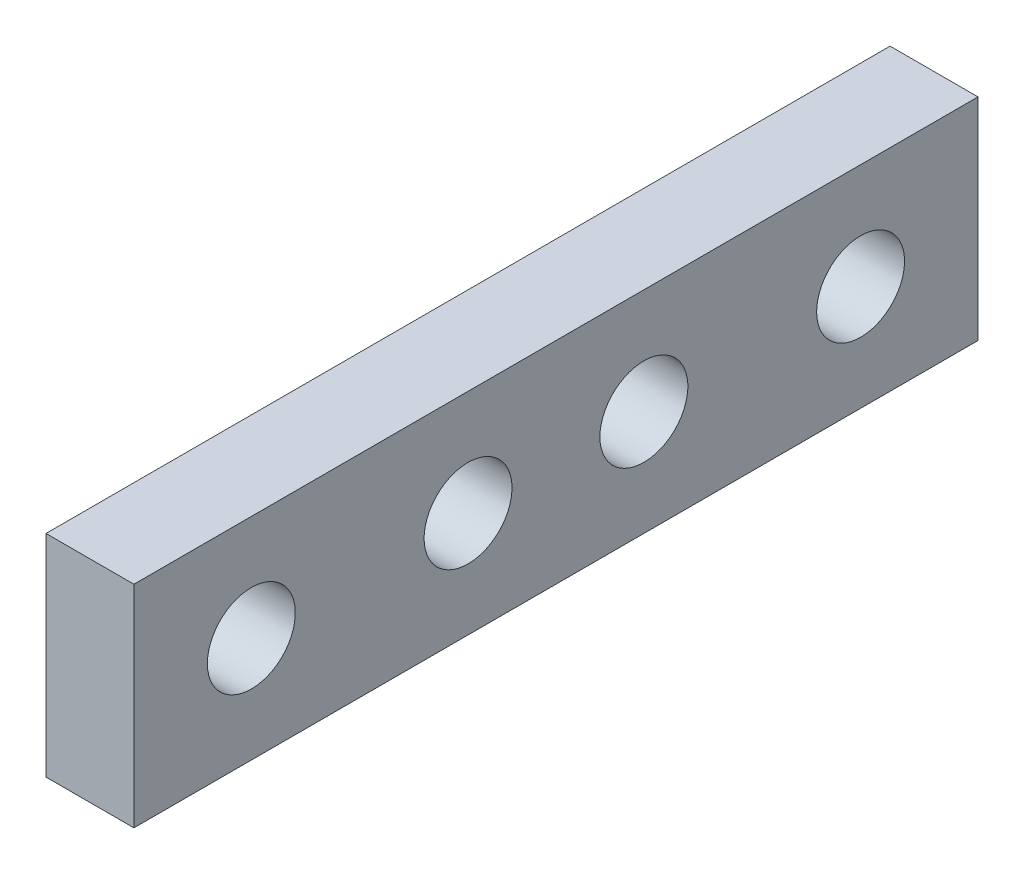
from build123d import *

# Parameters (mm, degrees)
SKETCH1_W           = 3.175
SKETCH1_H           = 7.62
BOSS_EXTRUDE1_DEPTH = 15.24
SKETCH3_R           = 1.5875
CUT_EXTRUDE2_DEPTH  = 4.175
SKETCH5_R           = 1.5875
CUT_EXTRUDE4_DEPTH  = 4.175


with BuildPart() as part:
    # Sketch1 → Boss-Extrude1 (new body)
    with BuildSketch(Plane.XY):
        Rectangle(SKETCH1_W, SKETCH1_H)
    boss_extrude1 = extrude(amount=BOSS_EXTRUDE1_DEPTH)

    # Mirror1: Boss-Extrude1 across plane
    add(boss_extrude1.mirror(Plane.XY))

    # Sketch3 → Cut-Extrude2 (cut, through all)
    with BuildSketch(Plane.ZY.offset(1.5875)):
        with Locations((-3.175, 0)):
            Circle(SKETCH3_R)
        with Locations((3.175, 0)):
            Circle(SKETCH3_R)
    extrude(amount=-CUT_EXTRUDE2_DEPTH, mode=Mode.SUBTRACT)

    # Sketch5 → Cut-Extrude4 (cut, through all)
    with BuildSketch(Plane.ZY.offset(1.5875)):
        with Locations((-11, 0)):
            Circle(SKETCH5_R)
        with Locations((11, 0)):
            Circle(SKETCH5_R)
    extrude(amount=-CUT_EXTRUDE4_DEPTH, mode=Mode.SUBTRACT)


solid = part.part
